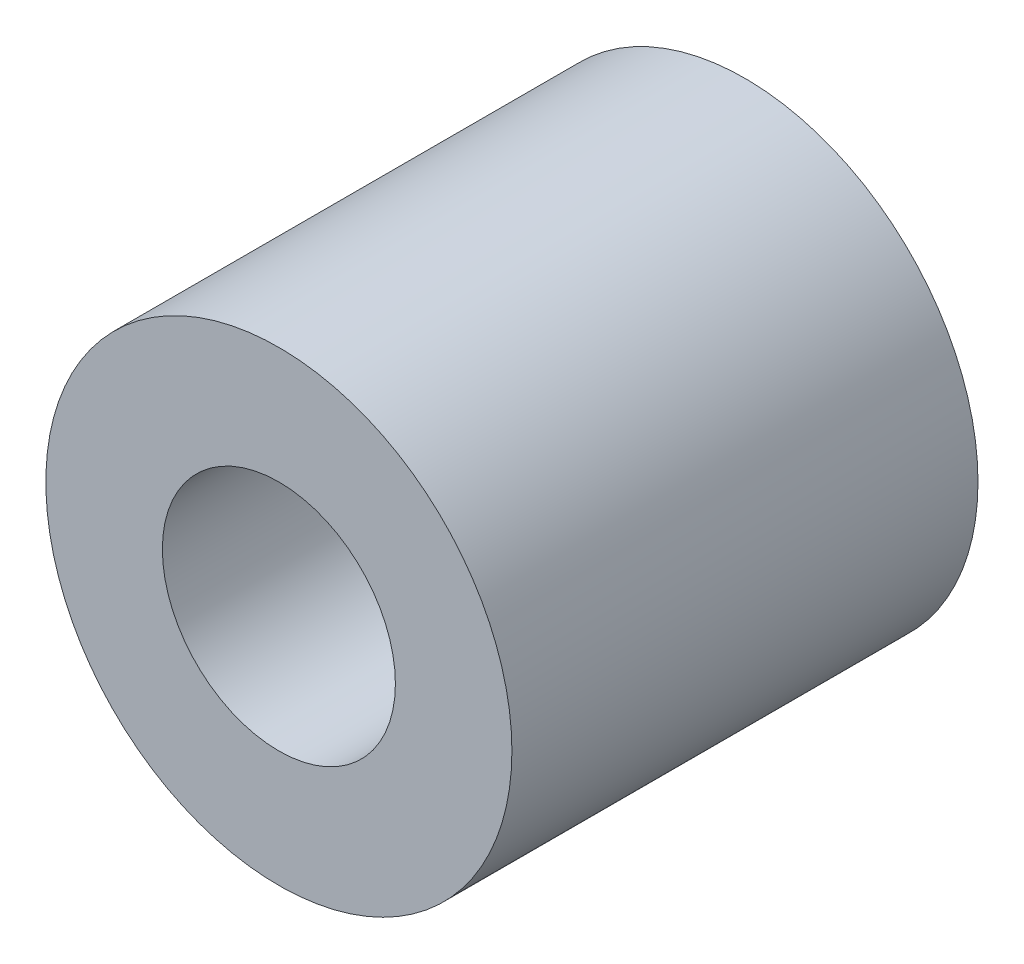
from build123d import *

# Parameters (mm, degrees)
SKETCH1_R      = 3.175
SKETCH1_R_2    = 1.5875
EXTRUDE1_DEPTH = 3.175


with BuildPart() as part:
    # Sketch1 → Extrude1 (new body, symmetric)
    with BuildSketch(Plane.XY):
        Circle(SKETCH1_R)
        Circle(SKETCH1_R_2, mode=Mode.SUBTRACT)
    extrude(amount=EXTRUDE1_DEPTH, both=True)


solid = part.part
